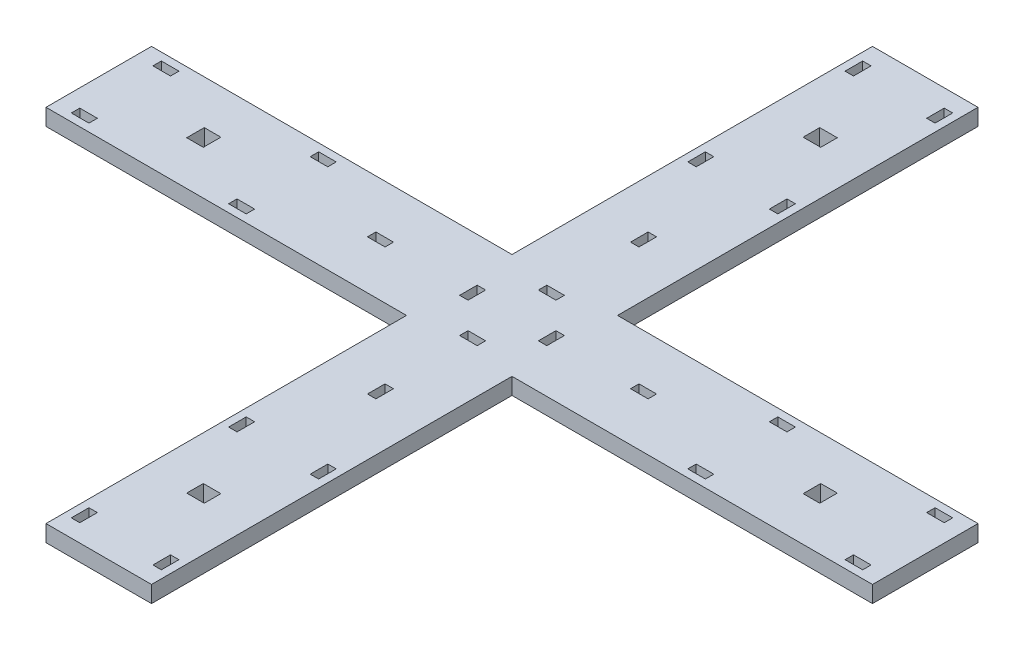
from build123d import *

# Parameters (mm, degrees)
SKETCH1_W           = 3.048
SKETCH1_H           = 6.35
SKETCH1_W_2         = 6.35
SKETCH1_H_2         = 3.048
SKETCH1_W_3         = 5.9944
SKETCH1_H_3         = 5.9944
BOSS_EXTRUDE1_DEPTH = 5.9944


with BuildPart() as part:
    # Sketch1 → Boss-Extrude1 (new body)
    with BuildSketch(Plane(origin=(0, 0, 0), x_dir=(1, 0, 0), z_dir=(0, 1, 0))):
        Polygon((130.175, 0), (130.175, 130.175), (0, 130.175), (0, 168.275), (130.175, 168.275), (130.175, 298.45), (168.275, 298.45), (168.275, 168.275), (298.45, 168.275), (298.45, 130.175), (168.275, 130.175), (168.275, 0), align=None)
        with Locations((163.957, 9.525)):
            Rectangle(SKETCH1_W, SKETCH1_H, mode=Mode.SUBTRACT)
        with Locations((134.493, 9.525)):
            Rectangle(SKETCH1_W, SKETCH1_H, mode=Mode.SUBTRACT)
        with Locations((288.925, 163.957)):
            Rectangle(SKETCH1_W_2, SKETCH1_H_2, mode=Mode.SUBTRACT)
        with Locations((288.925, 134.493)):
            Rectangle(SKETCH1_W_2, SKETCH1_H_2, mode=Mode.SUBTRACT)
        with Locations((149.225, 196.723)):
            Rectangle(SKETCH1_W, SKETCH1_H, mode=Mode.SUBTRACT)
        with Locations((101.727, 149.225)):
            Rectangle(SKETCH1_W_2, SKETCH1_H_2, mode=Mode.SUBTRACT)
        with Locations((149.225, 163.449)):
            Rectangle(SKETCH1_W_2, SKETCH1_H_2, mode=Mode.SUBTRACT)
        with Locations((135.001, 149.225)):
            Rectangle(SKETCH1_W, SKETCH1_H, mode=Mode.SUBTRACT)
        with Locations((163.449, 149.225)):
            Rectangle(SKETCH1_W, SKETCH1_H, mode=Mode.SUBTRACT)
        with Locations((196.723, 149.225)):
            Rectangle(SKETCH1_W_2, SKETCH1_H_2, mode=Mode.SUBTRACT)
        with Locations((149.225, 135.001)):
            Rectangle(SKETCH1_W_2, SKETCH1_H_2, mode=Mode.SUBTRACT)
        with Locations((149.225, 101.727)):
            Rectangle(SKETCH1_W, SKETCH1_H, mode=Mode.SUBTRACT)
        with Locations((134.493, 66.3194)):
            Rectangle(SKETCH1_W, SKETCH1_H, mode=Mode.SUBTRACT)
        with Locations((163.957, 66.3194)):
            Rectangle(SKETCH1_W, SKETCH1_H, mode=Mode.SUBTRACT)
        with Locations((232.1306, 134.493)):
            Rectangle(SKETCH1_W_2, SKETCH1_H_2, mode=Mode.SUBTRACT)
        with Locations((232.1306, 163.957)):
            Rectangle(SKETCH1_W_2, SKETCH1_H_2, mode=Mode.SUBTRACT)
        with Locations((260.5278, 149.225)):
            Rectangle(SKETCH1_W_3, SKETCH1_H, mode=Mode.SUBTRACT)
        with Locations((149.225, 37.9222)):
            Rectangle(SKETCH1_W_2, SKETCH1_H_3, mode=Mode.SUBTRACT)
        with Locations((149.225, 260.5278)):
            Rectangle(SKETCH1_W_2, SKETCH1_H_3, mode=Mode.SUBTRACT)
        with Locations((163.957, 232.1306)):
            Rectangle(SKETCH1_W, SKETCH1_H, mode=Mode.SUBTRACT)
        with Locations((134.493, 232.1306)):
            Rectangle(SKETCH1_W, SKETCH1_H, mode=Mode.SUBTRACT)
        with Locations((134.493, 288.925)):
            Rectangle(SKETCH1_W, SKETCH1_H, mode=Mode.SUBTRACT)
        with Locations((163.957, 288.925)):
            Rectangle(SKETCH1_W, SKETCH1_H, mode=Mode.SUBTRACT)
        with Locations((37.9222, 149.225)):
            Rectangle(SKETCH1_W_3, SKETCH1_H, mode=Mode.SUBTRACT)
        with Locations((66.3194, 163.957)):
            Rectangle(SKETCH1_W_2, SKETCH1_H_2, mode=Mode.SUBTRACT)
        with Locations((66.3194, 134.493)):
            Rectangle(SKETCH1_W_2, SKETCH1_H_2, mode=Mode.SUBTRACT)
        with Locations((9.525, 134.493)):
            Rectangle(SKETCH1_W_2, SKETCH1_H_2, mode=Mode.SUBTRACT)
        with Locations((9.525, 163.957)):
            Rectangle(SKETCH1_W_2, SKETCH1_H_2, mode=Mode.SUBTRACT)
    extrude(amount=BOSS_EXTRUDE1_DEPTH)


solid = part.part
